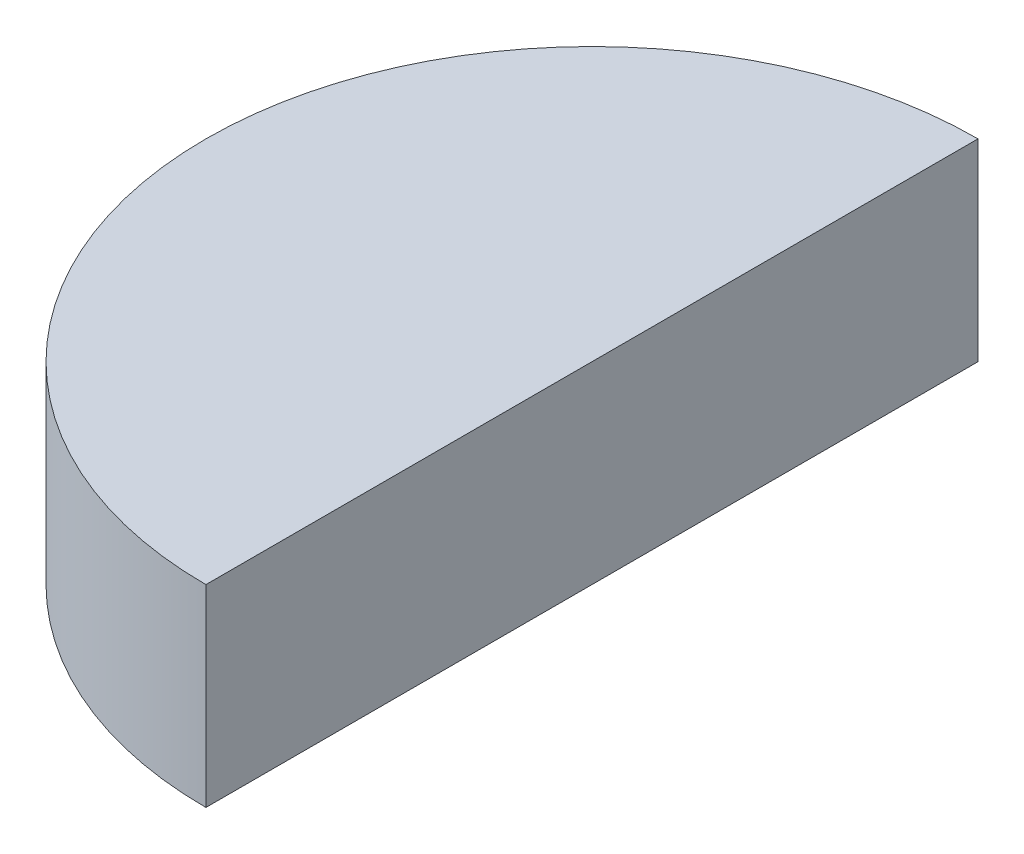
from build123d import *

# Parameters (mm, degrees)
SKETCH5_W      = 10000
SKETCH5_H      = 5000
REVOLVE1_ANGLE = 180


with BuildPart() as part:
    # Sketch5 → Revolve1 (revolve)
    with BuildSketch(Plane(origin=(0, 0, 0), x_dir=(0, 0, -1), z_dir=(1, 0, 0))):
        with Locations((5000, 2500)):
            Rectangle(SKETCH5_W, SKETCH5_H)
    revolve(axis=Axis((0, 0, 0), (0, 1, 0)), revolution_arc=REVOLVE1_ANGLE)


solid = part.part
